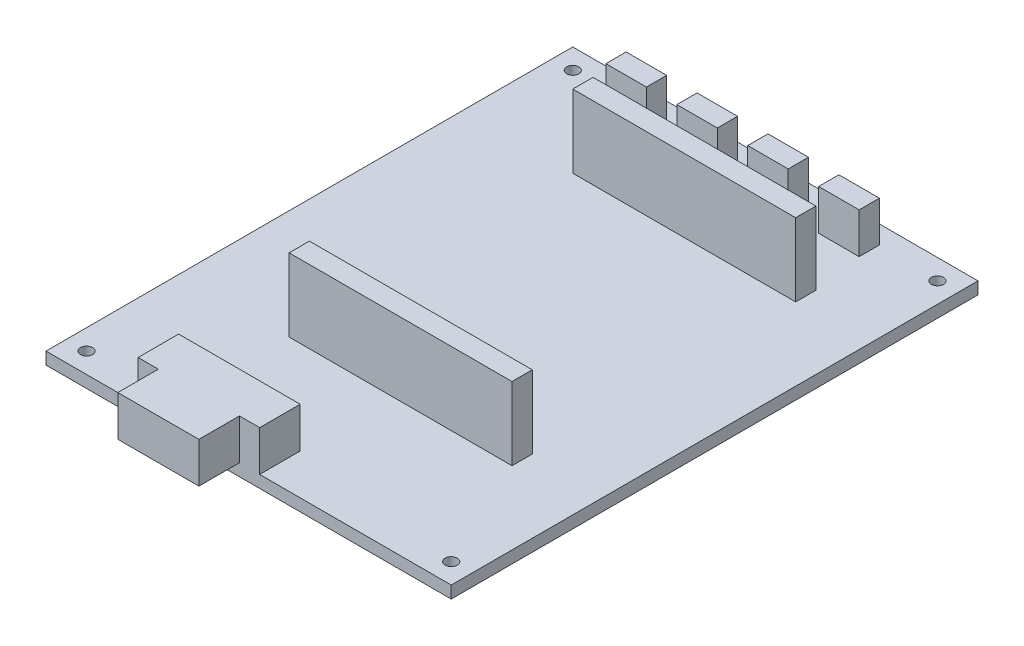
from build123d import *

# Parameters (mm, degrees)
ESQUISSE1_W      = 100
ESQUISSE1_H      = 130
ESQUISSE1_R      = 1.5
EXTRUSION1_DEPTH = 3
ESQUISSE2_W      = 55
ESQUISSE2_H      = 5
EXTRUSION2_DEPTH = 18
EXTRUSION3_DEPTH = 10
ESQUISSE4_W      = 10
ESQUISSE4_H      = 5
EXTRUSION4_DEPTH = 10


with BuildPart() as part:
    # Esquisse1 → Extrusion1 (new body)
    with BuildSketch(Plane(origin=(0, 0, 0), x_dir=(1, 0, 0), z_dir=(0, 1, 0))):
        with Locations((50, 65)):
            Rectangle(ESQUISSE1_W, ESQUISSE1_H)
        with Locations((5, 125)):
            Circle(ESQUISSE1_R, mode=Mode.SUBTRACT)
        with Locations((95, 125)):
            Circle(ESQUISSE1_R, mode=Mode.SUBTRACT)
        with Locations((95, 5)):
            Circle(ESQUISSE1_R, mode=Mode.SUBTRACT)
        with Locations((5, 5)):
            Circle(ESQUISSE1_R, mode=Mode.SUBTRACT)
    extrude(amount=EXTRUSION1_DEPTH)

    # Esquisse2 → Extrusion2 (add)
    with BuildSketch(Plane(origin=(0, 3, 0), x_dir=(1, 0, 0), z_dir=(0, 1, 0))):
        with Locations((54.5, 105.5)):
            Rectangle(ESQUISSE2_W, ESQUISSE2_H)
        with Locations((54.5, 35.5)):
            Rectangle(ESQUISSE2_W, ESQUISSE2_H)
    extrude(amount=EXTRUSION2_DEPTH)

    # Esquisse3 → Extrusion3 (add)
    with BuildSketch(Plane(origin=(0, 3, 0), x_dir=(1, 0, 0), z_dir=(0, 1, 0))):
        Polygon((22.725382584, 0), (22.725382584, 10), (52.725382584, 10), (52.725382584, 0), (47.725382584, 0), (47.725382584, -10), (27.725382584, -10), (27.725382584, 0), align=None)
    extrude(amount=EXTRUSION3_DEPTH)

    # Esquisse4 → Extrusion4 (add)
    with BuildSketch(Plane(origin=(0, 3, 0), x_dir=(1, 0, 0), z_dir=(0, 1, 0))):
        with Locations((22.654691777, 123.012698359)):
            Rectangle(ESQUISSE4_W, ESQUISSE4_H)
        with Locations((40.154691777, 123.012698359)):
            Rectangle(ESQUISSE4_W, ESQUISSE4_H)
        with Locations((57.654691777, 123.012698359)):
            Rectangle(ESQUISSE4_W, ESQUISSE4_H)
        with Locations((75.154691777, 123.012698359)):
            Rectangle(ESQUISSE4_W, ESQUISSE4_H)
    extrude(amount=EXTRUSION4_DEPTH)


solid = part.part
